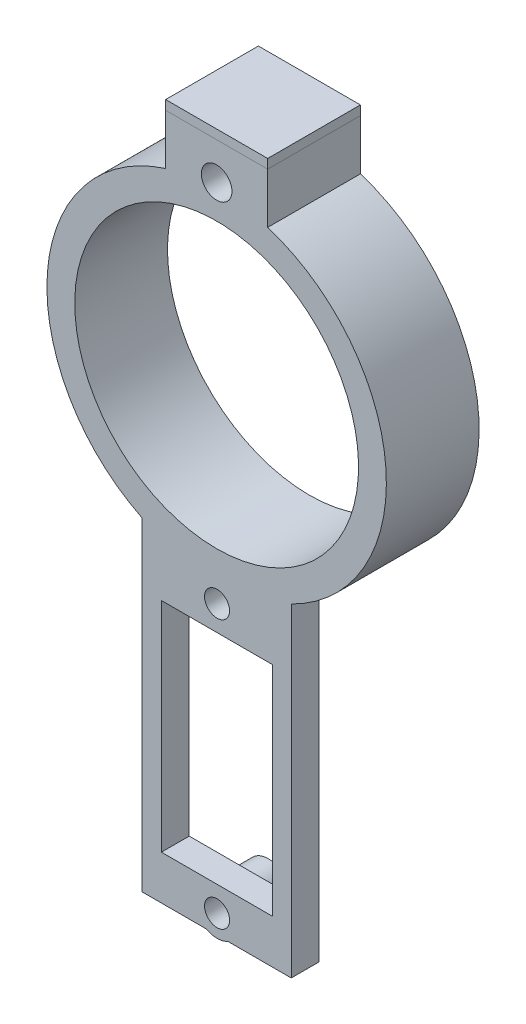
from build123d import *

# Parameters (mm, degrees)
SKETCH2_R       = 18.3
SKETCH2_R_2     = 15.3
EXTRUDE1_DEPTH  = 10
SKETCH3_W       = 16.087912088
SKETCH3_H       = 34.925770001
SKETCH3_W_2     = 12
SKETCH3_H_2     = 23.5
EXTRUDE2_DEPTH  = 3
SKETCH4_W       = 7
SKETCH4_H       = 3.40570579
EXTRUDE3_DEPTH  = 11
SKETCH5_W       = 7
SKETCH5_H       = 8
EXTRUDE4_DEPTH  = 10
EXTRUDE5_DEPTH  = 7
SKETCH7_W       = 10
SKETCH7_H       = 8
EXTRUDE6_DEPTH  = 2
SKETCH8_W       = 10
SKETCH8_H       = 8
EXTRUDE7_DEPTH  = 2
SKETCH9_W       = 11
SKETCH9_H       = 10
EXTRUDE9_DEPTH  = 1
SKETCH10_R      = 1.65
EXTRUDE10_DEPTH = 4.2
SKETCH11_R      = 1.15
EXTRUDE12_DEPTH = 6.8
SKETCH12_R      = 15.3
EXTRUDE13_DEPTH = 11
SKETCH29_R      = 2.35
EXTRUDE30_DEPTH = 5.5
SKETCH31_R      = 1.35
EXTRUDE31_DEPTH = 3.5


with BuildPart() as part:
    # Sketch2 → Extrude1 (new body)
    with BuildSketch(Plane.XY):
        Circle(SKETCH2_R)
        Circle(SKETCH2_R_2, mode=Mode.SUBTRACT)
    extrude(amount=EXTRUDE1_DEPTH)

    # Sketch3 → Extrude2 (add)
    with BuildSketch(Plane.XY.offset(10)):
        with Locations((0, -33.900183172)):
            Rectangle(SKETCH3_W, SKETCH3_H)
        with Locations((0.043956044, -34.863068172)):
            Rectangle(SKETCH3_W_2, SKETCH3_H_2, mode=Mode.SUBTRACT)
    extrude(amount=-EXTRUDE2_DEPTH)

    # Sketch4 → Extrude3 (cut, through all)
    with BuildSketch(Plane(origin=(0, 0, 0), x_dir=(-1, 0, 0), z_dir=(0, 0, -1))):
        with Locations((0, 16.597147105)):
            Rectangle(SKETCH4_W, SKETCH4_H)
    extrude(amount=-EXTRUDE3_DEPTH, mode=Mode.SUBTRACT)



with BuildPart() as body_2:
    # Sketch5 → Extrude4 (new body)
    with BuildSketch(Plane(origin=(0, 0, 0), x_dir=(-1, 0, 0), z_dir=(0, 0, -1))):
        with Locations((0, 18.89429421)):
            Rectangle(SKETCH5_W, SKETCH5_H)
    extrude(amount=-EXTRUDE4_DEPTH)

    # Sketch6 → Extrude5 (cut)
    with BuildSketch(Plane.ZY.offset(3.5)):
        Polygon((10, 14.89429421), (0, 22.89429421), (0, 14.89429421), align=None)
    extrude(amount=-EXTRUDE5_DEPTH, mode=Mode.SUBTRACT)


with BuildPart() as part_1:
    add(part.part)

    add(body_2.part)  # Extrude6 merges body 2
    # Sketch7 → Extrude6 (add)
    with BuildSketch(Plane.ZY.offset(3.5)):
        with Locations((5, 18.89429421)):
            Rectangle(SKETCH7_W, SKETCH7_H)
    extrude(amount=EXTRUDE6_DEPTH)

    # Sketch8 → Extrude7 (add)
    with BuildSketch(Plane(origin=(3.5, 0, 0), x_dir=(0, 0, -1), z_dir=(1, 0, 0))):
        with Locations((-5, 18.89429421)):
            Rectangle(SKETCH8_W, SKETCH8_H)
    extrude(amount=EXTRUDE7_DEPTH)

    # Sketch10 → Extrude10 (cut)
    with BuildSketch(Plane.XY.offset(10)):
        with Locations((0, 18.89429421)):
            Circle(SKETCH10_R)
    extrude(amount=-EXTRUDE10_DEPTH, mode=Mode.SUBTRACT)

    # Sketch11 → Extrude12 (cut, through all)
    with BuildSketch(Plane.XY.offset(5.8)):
        with Locations((0, 18.89429421)):
            Circle(SKETCH11_R)
    extrude(amount=-EXTRUDE12_DEPTH, mode=Mode.SUBTRACT)

    # Sketch12 → Extrude13 (cut, through all)
    with BuildSketch(Plane(origin=(0, 0, 0), x_dir=(-1, 0, 0), z_dir=(0, 0, -1))):
        Circle(SKETCH12_R)
    extrude(amount=-EXTRUDE13_DEPTH, mode=Mode.SUBTRACT)

    # Sketch29 → Extrude30 (add)
    with BuildSketch(Plane.XY.offset(10)):
        with Locations((0.043956044, -20.413068172)):
            Circle(SKETCH29_R)
        with Locations((0.046502138, -49.313066971)):
            Circle(SKETCH29_R)
    extrude(amount=-EXTRUDE30_DEPTH)

    # Sketch31 → Extrude31 (cut)
    with BuildSketch(Plane.XY.offset(10)):
        with Locations((0.046502138, -49.313066971)):
            Circle(SKETCH31_R)
        with Locations((0.043956044, -20.413068172)):
            Circle(SKETCH31_R)
    extrude(amount=-EXTRUDE31_DEPTH, mode=Mode.SUBTRACT)


with BuildPart() as body_2_2:
    # Sketch9 → Extrude9 (new body)
    with BuildSketch(Plane(origin=(0, 22.89429421, 0), x_dir=(1, 0, 0), z_dir=(0, 1, 0))):
        with Locations((0, -5)):
            Rectangle(SKETCH9_W, SKETCH9_H)
    extrude(amount=EXTRUDE9_DEPTH)


solid = Compound([part_1.part, body_2_2.part])
